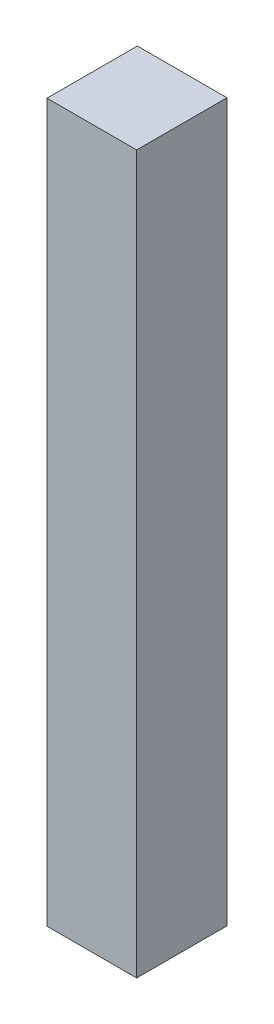
from build123d import *

# Parameters (mm, degrees)
SKETCH1_W           = 3.175
SKETCH1_H           = 3.2004
BOSS_EXTRUDE1_DEPTH = 25.4


with BuildPart() as part:
    # Sketch1 → Boss-Extrude1 (new body)
    with BuildSketch(Plane(origin=(0, 0, 0), x_dir=(1, 0, 0), z_dir=(0, 1, 0))):
        with Locations((1.5875, 1.6002)):
            Rectangle(SKETCH1_W, SKETCH1_H)
    extrude(amount=BOSS_EXTRUDE1_DEPTH)


solid = part.part
